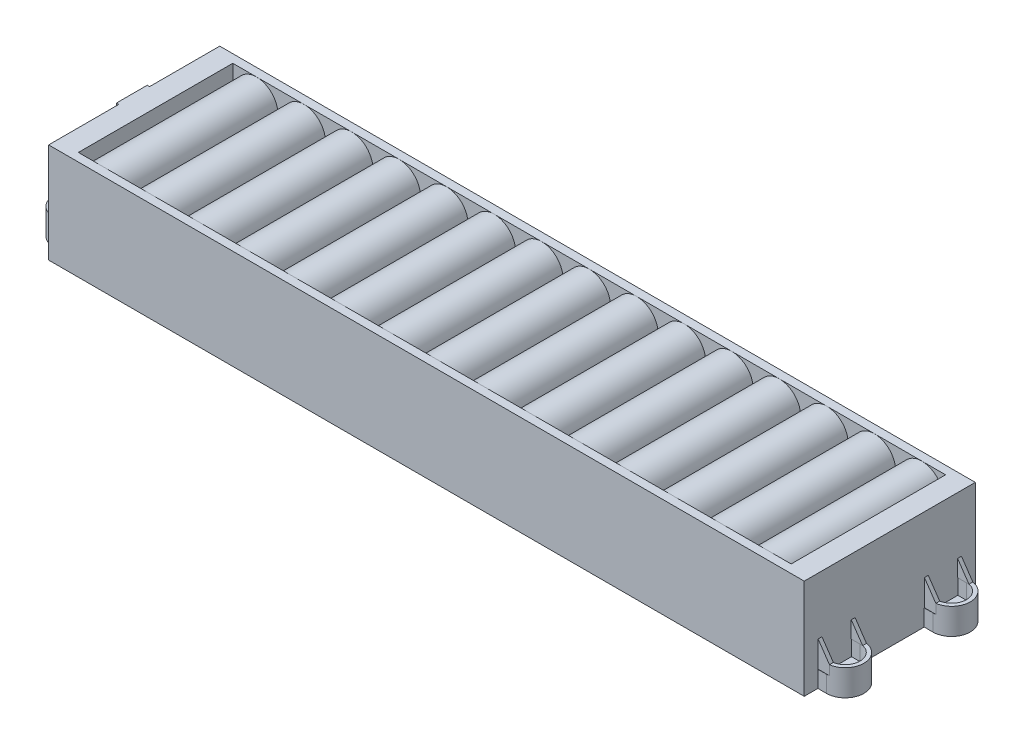
from build123d import *

# Parameters (mm, degrees)
SKETCH1_W                                = 318
SKETCH1_H                                = 72
BOSS_EXTRUDE1_DEPTH                      = 42
BOSS_EXTRUDE2_DEPTH                      = 11
BOSS_EXTRUDE2_2_DEPTH                    = 11
BOSS_EXTRUDE2_3_DEPTH                    = 11
BOSS_EXTRUDE2_4_DEPTH                    = 11
BOSS_EXTRUDE3_DEPTH                      = 4.5
MIRROR5_AT_THE_SECOND_PLANE_COPY_1_DEPTH = 4.5
CUT_EXTRUDE1_DEPTH                       = 32.5
LPATTERN1_COUNT                          = 15
LPATTERN1_PITCH                          = 20
MIRROR7_COPY_1_DEPTH                     = 32.5
MIRROR7_COPY_2_DEPTH                     = 32.5
MIRROR7_COPY_3_DEPTH                     = 32.5
MIRROR7_COPY_4_DEPTH                     = 32.5
MIRROR7_COPY_5_DEPTH                     = 32.5
MIRROR7_COPY_6_DEPTH                     = 32.5
MIRROR7_COPY_7_DEPTH                     = 32.5
MIRROR7_COPY_8_DEPTH                     = 32.5
MIRROR7_COPY_9_DEPTH                     = 32.5
MIRROR7_COPY_10_DEPTH                    = 32.5
MIRROR7_COPY_11_DEPTH                    = 32.5
MIRROR7_COPY_12_DEPTH                    = 32.5
MIRROR7_COPY_13_DEPTH                    = 32.5
MIRROR7_COPY_14_DEPTH                    = 32.5
BOSS_EXTRUDE4_DEPTH                      = 72
SKETCH6_W                                = 4.8
SKETCH6_H                                = 5.838152114
SKETCH6_H_2                              = 12.328016872
SKETCH6_H_3                              = 29.176304228
CUT_EXTRUDE2_DEPTH                       = 35
SKETCH7_W                                = 13
SKETCH7_H                                = 10
BOSS_EXTRUDE5_DEPTH                      = 1


with BuildPart() as part:
    # Sketch1 → Boss-Extrude1 (new body)
    with BuildSketch(Plane(origin=(0, 0, 0), x_dir=(1, 0, 0), z_dir=(0, 1, 0))):
        Rectangle(SKETCH1_W, SKETCH1_H)
    extrude(amount=BOSS_EXTRUDE1_DEPTH)



with BuildPart() as body_2:
    # Sketch2 → Boss-Extrude2 (new body)
    with BuildSketch(Plane.XZ):
        with BuildLine():
            Line((162.625, 14.5), (159, 14.5))
            Line((159, 14.5), (159, 16.1))
            Line((159, 16.1), (162.625, 16.1))
            ThreePointArc((162.625, 16.1), (168.9, 22.375), (162.625, 28.65))
            Line((162.625, 28.65), (159, 28.65))
            Line((159, 28.65), (159, 30.25))
            Line((159, 30.25), (162.625, 30.25))
            ThreePointArc((162.625, 30.25), (170.5, 22.375), (162.625, 14.5))
        make_face()
    extrude(amount=-BOSS_EXTRUDE2_DEPTH)


with BuildPart() as body_3:
    # Sketch2 → Boss-Extrude2 2 (new body)
    with BuildSketch(Plane.XZ):
        with BuildLine():
            Line((162.625, -14.5), (159, -14.5))
            Line((159, -14.5), (159, -16.1))
            Line((159, -16.1), (162.625, -16.1))
            ThreePointArc((162.625, -16.1), (168.9, -22.375), (162.625, -28.65))
            Line((162.625, -28.65), (159, -28.65))
            Line((159, -28.65), (159, -30.25))
            Line((159, -30.25), (162.625, -30.25))
            ThreePointArc((162.625, -30.25), (170.5, -22.375), (162.625, -14.5))
        make_face()
    extrude(amount=-BOSS_EXTRUDE2_2_DEPTH)


with BuildPart() as body_4:
    # Sketch2 → Boss-Extrude2 3 (new body)
    with BuildSketch(Plane.XZ):
        with BuildLine():
            Line((-162.625, -14.5), (-159, -14.5))
            Line((-159, -14.5), (-159, -16.1))
            Line((-159, -16.1), (-162.625, -16.1))
            ThreePointArc((-162.625, -16.1), (-168.9, -22.375), (-162.625, -28.65))
            Line((-162.625, -28.65), (-159, -28.65))
            Line((-159, -28.65), (-159, -30.25))
            Line((-159, -30.25), (-162.625, -30.25))
            ThreePointArc((-162.625, -30.25), (-170.5, -22.375), (-162.625, -14.5))
        make_face()
    extrude(amount=-BOSS_EXTRUDE2_3_DEPTH)


with BuildPart() as body_5:
    # Sketch2 → Boss-Extrude2 4 (new body)
    with BuildSketch(Plane.XZ):
        with BuildLine():
            Line((-162.625, 14.5), (-159, 14.5))
            Line((-159, 14.5), (-159, 16.1))
            Line((-159, 16.1), (-162.625, 16.1))
            ThreePointArc((-162.625, 16.1), (-168.9, 22.375), (-162.625, 28.65))
            Line((-162.625, 28.65), (-159, 28.65))
            Line((-159, 28.65), (-159, 30.25))
            Line((-159, 30.25), (-162.625, 30.25))
            ThreePointArc((-162.625, 30.25), (-170.5, 22.375), (-162.625, 14.5))
        make_face()
    extrude(amount=-BOSS_EXTRUDE2_4_DEPTH)


with BuildPart() as part_1:
    add(part.part)

    add(body_2.part)  # Boss-Extrude3 merges body 2
    # Sketch3 → Boss-Extrude3 (add)
    with BuildSketch(Plane.XZ):
        with BuildLine():
            Line((159, 28.65), (159, 16.1))
            Line((159, 16.1), (162.625, 16.1))
            ThreePointArc((162.625, 16.1), (168.9, 22.375), (162.625, 28.65))
            Line((162.625, 28.65), (159, 28.65))
        make_face()
        with BuildLine():
            Line((161.825, 24.55), (165.075, 24.55))
            ThreePointArc((165.075, 24.55), (167.25, 22.375), (165.075, 20.2))
            Line((165.075, 20.2), (161.825, 20.2))
            ThreePointArc((161.825, 20.2), (159.65, 22.375), (161.825, 24.55))
        make_face(mode=Mode.SUBTRACT)
    boss_extrude3 = extrude(amount=-BOSS_EXTRUDE3_DEPTH)

    # Mirror5: Boss-Extrude3 across plane
    add(boss_extrude3.mirror(Plane(origin=(0, 0, 0), x_dir=(0, 0, 1), z_dir=(1, 0, 0))))

    # Mirror5 at the second plane: Boss-Extrude3 across plane
    add(boss_extrude3.mirror(Plane.XY))

    # Mirror5 at the second plane copy 1 sketc → Mirror5 at the second plane copy 1 (add)
    with BuildSketch(Plane(origin=(0, 0, 0), x_dir=(-1, 0, 0), z_dir=(0, -1, 0))):
        with BuildLine():
            Line((159, 28.65), (159, 16.1))
            Line((159, 16.1), (162.625, 16.1))
            ThreePointArc((162.625, 16.1), (168.9, 22.375), (162.625, 28.65))
            Line((162.625, 28.65), (159, 28.65))
        make_face()
        with BuildLine():
            Line((161.825, 24.55), (165.075, 24.55))
            ThreePointArc((165.075, 24.55), (167.25, 22.375), (165.075, 20.2))
            Line((165.075, 20.2), (161.825, 20.2))
            ThreePointArc((161.825, 20.2), (159.65, 22.375), (161.825, 24.55))
        make_face(mode=Mode.SUBTRACT)
    extrude(amount=-MIRROR5_AT_THE_SECOND_PLANE_COPY_1_DEPTH)

    # Sketch4 → Cut-Extrude1 (cut, symmetric)
    with BuildSketch(Plane.XY):
        with BuildLine():
            ThreePointArc((-149, 33), (-146.363961031, 39.363961031), (-140, 42))
            Line((-140, 42), (-150, 42))
            Line((-150, 42), (-150, 33))
            Line((-150, 33), (-149, 33))
        make_face()
        with BuildLine():
            ThreePointArc((-140, 42), (-133.636038969, 39.363961031), (-131, 33))
            Line((-131, 33), (-130, 33))
            Line((-130, 33), (-130, 42))
            Line((-130, 42), (-140, 42))
        make_face()
    cut_extrude1 = extrude(amount=CUT_EXTRUDE1_DEPTH, both=True, mode=Mode.SUBTRACT)

    # LPattern1: Cut-Extrude1 ×15
    with Locations(*[(i * LPATTERN1_PITCH, 0, 0) for i in range(1, LPATTERN1_COUNT)]):
        add(cut_extrude1, mode=Mode.SUBTRACT)

    # Mirror7: Cut-Extrude1 across plane
    add(cut_extrude1.mirror(Plane(origin=(0, 21, 0), x_dir=(0, 0, 1), z_dir=(0, -1, 0))), mode=Mode.SUBTRACT)

    # Mirror7 copy 1 sketch → Mirror7 copy 1 (cut, symmetric)
    with BuildSketch(Plane(origin=(20, 42, 0), x_dir=(1, 0, 0), z_dir=(0, 0, 1))):
        with BuildLine():
            ThreePointArc((-149, -33), (-146.363961031, -39.363961031), (-140, -42))
            Line((-140, -42), (-150, -42))
            Line((-150, -42), (-150, -33))
            Line((-150, -33), (-149, -33))
        make_face()
        with BuildLine():
            ThreePointArc((-140, -42), (-133.636038969, -39.363961031), (-131, -33))
            Line((-131, -33), (-130, -33))
            Line((-130, -33), (-130, -42))
            Line((-130, -42), (-140, -42))
        make_face()
    extrude(amount=MIRROR7_COPY_1_DEPTH, both=True, mode=Mode.SUBTRACT)

    # Mirror7 copy 2 sketch → Mirror7 copy 2 (cut, symmetric)
    with BuildSketch(Plane(origin=(40, 42, 0), x_dir=(1, 0, 0), z_dir=(0, 0, 1))):
        with BuildLine():
            ThreePointArc((-149, -33), (-146.363961031, -39.363961031), (-140, -42))
            Line((-140, -42), (-150, -42))
            Line((-150, -42), (-150, -33))
            Line((-150, -33), (-149, -33))
        make_face()
        with BuildLine():
            ThreePointArc((-140, -42), (-133.636038969, -39.363961031), (-131, -33))
            Line((-131, -33), (-130, -33))
            Line((-130, -33), (-130, -42))
            Line((-130, -42), (-140, -42))
        make_face()
    extrude(amount=MIRROR7_COPY_2_DEPTH, both=True, mode=Mode.SUBTRACT)

    # Mirror7 copy 3 sketch → Mirror7 copy 3 (cut, symmetric)
    with BuildSketch(Plane(origin=(60, 42, 0), x_dir=(1, 0, 0), z_dir=(0, 0, 1))):
        with BuildLine():
            ThreePointArc((-149, -33), (-146.363961031, -39.363961031), (-140, -42))
            Line((-140, -42), (-150, -42))
            Line((-150, -42), (-150, -33))
            Line((-150, -33), (-149, -33))
        make_face()
        with BuildLine():
            ThreePointArc((-140, -42), (-133.636038969, -39.363961031), (-131, -33))
            Line((-131, -33), (-130, -33))
            Line((-130, -33), (-130, -42))
            Line((-130, -42), (-140, -42))
        make_face()
    extrude(amount=MIRROR7_COPY_3_DEPTH, both=True, mode=Mode.SUBTRACT)

    # Mirror7 copy 4 sketch → Mirror7 copy 4 (cut, symmetric)
    with BuildSketch(Plane(origin=(80, 42, 0), x_dir=(1, 0, 0), z_dir=(0, 0, 1))):
        with BuildLine():
            ThreePointArc((-149, -33), (-146.363961031, -39.363961031), (-140, -42))
            Line((-140, -42), (-150, -42))
            Line((-150, -42), (-150, -33))
            Line((-150, -33), (-149, -33))
        make_face()
        with BuildLine():
            ThreePointArc((-140, -42), (-133.636038969, -39.363961031), (-131, -33))
            Line((-131, -33), (-130, -33))
            Line((-130, -33), (-130, -42))
            Line((-130, -42), (-140, -42))
        make_face()
    extrude(amount=MIRROR7_COPY_4_DEPTH, both=True, mode=Mode.SUBTRACT)

    # Mirror7 copy 5 sketch → Mirror7 copy 5 (cut, symmetric)
    with BuildSketch(Plane(origin=(100, 42, 0), x_dir=(1, 0, 0), z_dir=(0, 0, 1))):
        with BuildLine():
            ThreePointArc((-149, -33), (-146.363961031, -39.363961031), (-140, -42))
            Line((-140, -42), (-150, -42))
            Line((-150, -42), (-150, -33))
            Line((-150, -33), (-149, -33))
        make_face()
        with BuildLine():
            ThreePointArc((-140, -42), (-133.636038969, -39.363961031), (-131, -33))
            Line((-131, -33), (-130, -33))
            Line((-130, -33), (-130, -42))
            Line((-130, -42), (-140, -42))
        make_face()
    extrude(amount=MIRROR7_COPY_5_DEPTH, both=True, mode=Mode.SUBTRACT)

    # Mirror7 copy 6 sketch → Mirror7 copy 6 (cut, symmetric)
    with BuildSketch(Plane(origin=(120, 42, 0), x_dir=(1, 0, 0), z_dir=(0, 0, 1))):
        with BuildLine():
            ThreePointArc((-149, -33), (-146.363961031, -39.363961031), (-140, -42))
            Line((-140, -42), (-150, -42))
            Line((-150, -42), (-150, -33))
            Line((-150, -33), (-149, -33))
        make_face()
        with BuildLine():
            ThreePointArc((-140, -42), (-133.636038969, -39.363961031), (-131, -33))
            Line((-131, -33), (-130, -33))
            Line((-130, -33), (-130, -42))
            Line((-130, -42), (-140, -42))
        make_face()
    extrude(amount=MIRROR7_COPY_6_DEPTH, both=True, mode=Mode.SUBTRACT)

    # Mirror7 copy 7 sketch → Mirror7 copy 7 (cut, symmetric)
    with BuildSketch(Plane(origin=(140, 42, 0), x_dir=(1, 0, 0), z_dir=(0, 0, 1))):
        with BuildLine():
            ThreePointArc((-149, -33), (-146.363961031, -39.363961031), (-140, -42))
            Line((-140, -42), (-150, -42))
            Line((-150, -42), (-150, -33))
            Line((-150, -33), (-149, -33))
        make_face()
        with BuildLine():
            ThreePointArc((-140, -42), (-133.636038969, -39.363961031), (-131, -33))
            Line((-131, -33), (-130, -33))
            Line((-130, -33), (-130, -42))
            Line((-130, -42), (-140, -42))
        make_face()
    extrude(amount=MIRROR7_COPY_7_DEPTH, both=True, mode=Mode.SUBTRACT)

    # Mirror7 copy 8 sketch → Mirror7 copy 8 (cut, symmetric)
    with BuildSketch(Plane(origin=(160, 42, 0), x_dir=(1, 0, 0), z_dir=(0, 0, 1))):
        with BuildLine():
            ThreePointArc((-149, -33), (-146.363961031, -39.363961031), (-140, -42))
            Line((-140, -42), (-150, -42))
            Line((-150, -42), (-150, -33))
            Line((-150, -33), (-149, -33))
        make_face()
        with BuildLine():
            ThreePointArc((-140, -42), (-133.636038969, -39.363961031), (-131, -33))
            Line((-131, -33), (-130, -33))
            Line((-130, -33), (-130, -42))
            Line((-130, -42), (-140, -42))
        make_face()
    extrude(amount=MIRROR7_COPY_8_DEPTH, both=True, mode=Mode.SUBTRACT)

    # Mirror7 copy 9 sketch → Mirror7 copy 9 (cut, symmetric)
    with BuildSketch(Plane(origin=(180, 42, 0), x_dir=(1, 0, 0), z_dir=(0, 0, 1))):
        with BuildLine():
            ThreePointArc((-149, -33), (-146.363961031, -39.363961031), (-140, -42))
            Line((-140, -42), (-150, -42))
            Line((-150, -42), (-150, -33))
            Line((-150, -33), (-149, -33))
        make_face()
        with BuildLine():
            ThreePointArc((-140, -42), (-133.636038969, -39.363961031), (-131, -33))
            Line((-131, -33), (-130, -33))
            Line((-130, -33), (-130, -42))
            Line((-130, -42), (-140, -42))
        make_face()
    extrude(amount=MIRROR7_COPY_9_DEPTH, both=True, mode=Mode.SUBTRACT)

    # Mirror7 copy 10 sketch → Mirror7 copy 10 (cut, symmetric)
    with BuildSketch(Plane(origin=(200, 42, 0), x_dir=(1, 0, 0), z_dir=(0, 0, 1))):
        with BuildLine():
            ThreePointArc((-149, -33), (-146.363961031, -39.363961031), (-140, -42))
            Line((-140, -42), (-150, -42))
            Line((-150, -42), (-150, -33))
            Line((-150, -33), (-149, -33))
        make_face()
        with BuildLine():
            ThreePointArc((-140, -42), (-133.636038969, -39.363961031), (-131, -33))
            Line((-131, -33), (-130, -33))
            Line((-130, -33), (-130, -42))
            Line((-130, -42), (-140, -42))
        make_face()
    extrude(amount=MIRROR7_COPY_10_DEPTH, both=True, mode=Mode.SUBTRACT)

    # Mirror7 copy 11 sketch → Mirror7 copy 11 (cut, symmetric)
    with BuildSketch(Plane(origin=(220, 42, 0), x_dir=(1, 0, 0), z_dir=(0, 0, 1))):
        with BuildLine():
            ThreePointArc((-149, -33), (-146.363961031, -39.363961031), (-140, -42))
            Line((-140, -42), (-150, -42))
            Line((-150, -42), (-150, -33))
            Line((-150, -33), (-149, -33))
        make_face()
        with BuildLine():
            ThreePointArc((-140, -42), (-133.636038969, -39.363961031), (-131, -33))
            Line((-131, -33), (-130, -33))
            Line((-130, -33), (-130, -42))
            Line((-130, -42), (-140, -42))
        make_face()
    extrude(amount=MIRROR7_COPY_11_DEPTH, both=True, mode=Mode.SUBTRACT)

    # Mirror7 copy 12 sketch → Mirror7 copy 12 (cut, symmetric)
    with BuildSketch(Plane(origin=(240, 42, 0), x_dir=(1, 0, 0), z_dir=(0, 0, 1))):
        with BuildLine():
            ThreePointArc((-149, -33), (-146.363961031, -39.363961031), (-140, -42))
            Line((-140, -42), (-150, -42))
            Line((-150, -42), (-150, -33))
            Line((-150, -33), (-149, -33))
        make_face()
        with BuildLine():
            ThreePointArc((-140, -42), (-133.636038969, -39.363961031), (-131, -33))
            Line((-131, -33), (-130, -33))
            Line((-130, -33), (-130, -42))
            Line((-130, -42), (-140, -42))
        make_face()
    extrude(amount=MIRROR7_COPY_12_DEPTH, both=True, mode=Mode.SUBTRACT)

    # Mirror7 copy 13 sketch → Mirror7 copy 13 (cut, symmetric)
    with BuildSketch(Plane(origin=(260, 42, 0), x_dir=(1, 0, 0), z_dir=(0, 0, 1))):
        with BuildLine():
            ThreePointArc((-149, -33), (-146.363961031, -39.363961031), (-140, -42))
            Line((-140, -42), (-150, -42))
            Line((-150, -42), (-150, -33))
            Line((-150, -33), (-149, -33))
        make_face()
        with BuildLine():
            ThreePointArc((-140, -42), (-133.636038969, -39.363961031), (-131, -33))
            Line((-131, -33), (-130, -33))
            Line((-130, -33), (-130, -42))
            Line((-130, -42), (-140, -42))
        make_face()
    extrude(amount=MIRROR7_COPY_13_DEPTH, both=True, mode=Mode.SUBTRACT)

    # Mirror7 copy 14 sketch → Mirror7 copy 14 (cut, symmetric)
    with BuildSketch(Plane(origin=(280, 42, 0), x_dir=(1, 0, 0), z_dir=(0, 0, 1))):
        with BuildLine():
            ThreePointArc((-149, -33), (-146.363961031, -39.363961031), (-140, -42))
            Line((-140, -42), (-150, -42))
            Line((-150, -42), (-150, -33))
            Line((-150, -33), (-149, -33))
        make_face()
        with BuildLine():
            ThreePointArc((-140, -42), (-133.636038969, -39.363961031), (-131, -33))
            Line((-131, -33), (-130, -33))
            Line((-130, -33), (-130, -42))
            Line((-130, -42), (-140, -42))
        make_face()
    extrude(amount=MIRROR7_COPY_14_DEPTH, both=True, mode=Mode.SUBTRACT)


    add(body_3.part)  # Boss-Extrude4 merges body 3
    # Sketch5 → Boss-Extrude4 (add, through all)
    with BuildSketch(Plane.XY.offset(36)):
        Polygon((159, 11), (163.8, 11), (159, 18), align=None)
    extrude(amount=-BOSS_EXTRUDE4_DEPTH)

    # Sketch6 → Cut-Extrude2 (cut)
    with BuildSketch(Plane(origin=(0, 42, 0), x_dir=(1, 0, 0), z_dir=(0, 1, 0))):
        with Locations((161.4, -33.080923943)):
            Rectangle(SKETCH6_W, SKETCH6_H)
        with Locations((161.4, -22.375)):
            Rectangle(SKETCH6_W, SKETCH6_H_2)
        with Locations((161.4, 0)):
            Rectangle(SKETCH6_W, SKETCH6_H_3)
        with Locations((161.4, 22.375)):
            Rectangle(SKETCH6_W, SKETCH6_H_2)
        with Locations((161.4, 33.080923943)):
            Rectangle(SKETCH6_W, SKETCH6_H)
    extrude(amount=-CUT_EXTRUDE2_DEPTH, mode=Mode.SUBTRACT)

    # Sketch7 → Boss-Extrude5 (add)
    with BuildSketch(Plane.ZY.offset(159)):
        with Locations((0, 37)):
            Rectangle(SKETCH7_W, SKETCH7_H)
    extrude(amount=BOSS_EXTRUDE5_DEPTH)


solid = Compound([body_4.part, body_5.part, part_1.part])
